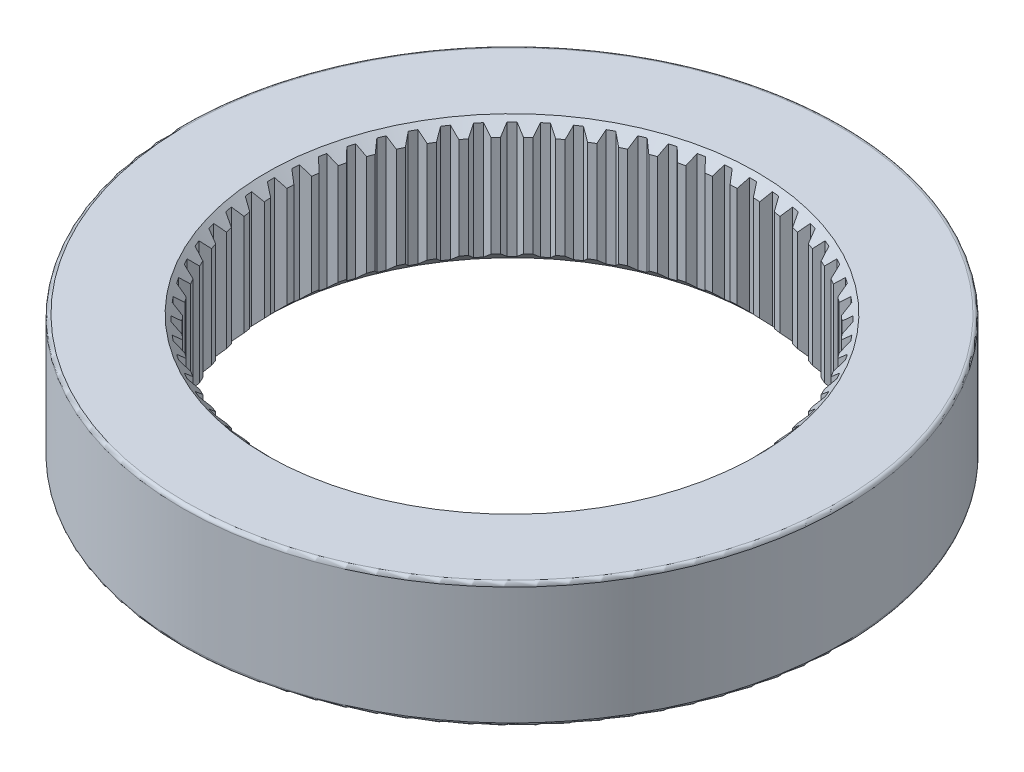
from build123d import *

# Parameters (mm, degrees)
SKETCH1_R           = 35.56
BOSS_EXTRUDE1_DEPTH = 13.462
SKETCH2_R           = 25.1841
CUT_EXTRUDE1_DEPTH  = 40.64
FILLET1_R           = 0.381
FILLET2_R           = 0.381
CHAMFER1_SIZE       = 1.2827
CHAMFER2_SIZE       = 1.2827
CUT_EXTRUDE2_DEPTH  = 13.462


with BuildPart() as part:
    # Sketch1 → Boss-Extrude1 (new body)
    with BuildSketch(Plane(origin=(0, 0, 0), x_dir=(1, 0, 0), z_dir=(0, 1, 0))):
        Circle(SKETCH1_R)
    extrude(amount=BOSS_EXTRUDE1_DEPTH)

    # Sketch2 → Cut-Extrude1 (cut)
    with BuildSketch(Plane(origin=(0, 13.462, 0), x_dir=(1, 0, 0), z_dir=(0, 1, 0))):
        Circle(SKETCH2_R)
    extrude(amount=-CUT_EXTRUDE1_DEPTH, mode=Mode.SUBTRACT)

    # Fillet1
    fillet1_edges = [part.edges().sort_by_distance(p)[0] for p in [
        (-35.56, 13.462, 0),
    ]]
    fillet(fillet1_edges, radius=FILLET1_R)

    # Fillet2
    fillet2_edges = [part.edges().sort_by_distance(p)[0] for p in [
        (-35.56, 0, 0),
    ]]
    fillet(fillet2_edges, radius=FILLET2_R)

    # Chamfer1
    chamfer1_edges = [part.edges().sort_by_distance(p)[0] for p in [
        (-25.1841, 13.462, 0),
    ]]
    chamfer(chamfer1_edges, length=CHAMFER1_SIZE)

    # Chamfer2
    chamfer2_edges = [part.edges().sort_by_distance(p)[0] for p in [
        (-25.1841, 0, 0),
    ]]
    chamfer(chamfer2_edges, length=CHAMFER2_SIZE)

    # Sketch3 → Cut-Extrude2 (cut)
    with BuildSketch(Plane(origin=(0, 13.462, 0), x_dir=(1, 0, 0), z_dir=(0, 1, 0))):
        with BuildLine():
            Line((-26.013050906, 0.384959402), (-25.143050032, 0.887254641))
            ThreePointArc((-25.143050032, 0.887254641), (-25.1587, 0), (-25.143050032, -0.887254641))
            Line((-25.143050032, -0.887254641), (-26.013050906, -0.384959402))
            ThreePointArc((-26.013050906, -0.384959402), (-26.0158992, 0), (-26.013050906, 0.384959402))
        make_face()
        with BuildLine():
            Line((-25.925523576, 2.166619143), (-25.108945536, 1.581467595))
            ThreePointArc((-25.108945536, 1.581467595), (-25.037553983, 2.465983828), (-24.935013211, 3.347432131))
            Line((-24.935013211, 3.347432131), (-25.850058336, 2.932830579))
            ThreePointArc((-25.850058336, 2.932830579), (-25.890625534, 2.550004043), (-25.925523576, 2.166619143))
        make_face()
        with BuildLine():
            Line((-25.588319281, 4.697331962), (-24.833028169, 4.034959435))
            ThreePointArc((-24.833028169, 4.034959435), (-24.675282634, 4.908218885), (-24.486838582, 5.775372019))
            Line((-24.486838582, 5.775372019), (-25.438115573, 5.452456993))
            ThreePointArc((-25.438115573, 5.452456993), (-25.516010992, 5.075450152), (-25.588319281, 4.697331962))
        make_face()
        with BuildLine():
            Line((-25.004685483, 7.182806907), (-24.317955166, 6.449592409))
            ThreePointArc((-24.317955166, 6.449592409), (-24.075374825, 7.30318511), (-23.802842311, 8.147691918))
            Line((-23.802842311, 8.147691918), (-24.781189852, 7.919573266))
            ThreePointArc((-24.781189852, 7.919573266), (-24.895663315, 7.552016903), (-25.004685483, 7.182806907))
        make_face()
        with BuildLine():
            Line((-24.180242896, 9.599107494), (-23.568686961, 8.802112283))
            ThreePointArc((-23.568686961, 8.802112283), (-23.243607995, 9.62781767), (-22.889611658, 10.44154509))
            Line((-22.889611658, 10.44154509), (-23.885607725, 10.31041972))
            ThreePointArc((-23.885607725, 10.31041972), (-24.035556791, 9.955853602), (-24.180242896, 9.599107494))
        make_face()
        with BuildLine():
            Line((-23.122931351, 11.922963429), (-22.592439416, 11.069863004))
            ThreePointArc((-22.592439416, 11.069863004), (-22.187992513, 11.859729083), (-21.755941531, 12.634840474))
            Line((-21.755941531, 12.634840474), (-22.759994139, 12.601971195))
            ThreePointArc((-22.759994139, 12.601971195), (-22.943974716, 12.263809988), (-23.122931351, 11.922963429))
        make_face()
        with BuildLine():
            Line((-21.842933337, 14.131994708), (-21.39861433, 13.231004892))
            ThreePointArc((-21.39861433, 13.231004892), (-20.918694535, 13.977424821), (-20.412749794, 14.706455438))
            Line((-20.412749794, 14.706455438), (-21.415189367, 14.772158798))
            ThreePointArc((-21.415189367, 14.772158798), (-21.631429622, 14.453659181), (-21.842933337, 14.131994708))
        make_face()
        with BuildLine():
            Line((-20.352575934, 16.204927153), (-19.99870889, 15.264724971))
            ThreePointArc((-19.99870889, 15.264724971), (-19.447938093, 15.960510318), (-18.872972118, 16.636439196))
            Line((-18.872972118, 16.636439196), (-19.864144615, 16.800082438))
            ThreePointArc((-19.864144615, 16.800082438), (-20.110562035, 16.504311734), (-20.352575934, 16.204927153))
        make_face()
        with BuildLine():
            Line((-18.666212099, 18.121797291), (-18.406204951, 17.151437403))
            ThreePointArc((-18.406204951, 17.151437403), (-17.789887376, 17.789887376), (-17.151437403, 18.406204951))
            Line((-17.151437403, 18.406204951), (-18.121797291, 18.666212099))
            ThreePointArc((-18.121797291, 18.666212099), (-18.396018743, 18.396018743), (-18.666212099, 18.121797291))
        make_face()
        with BuildLine():
            Line((-16.800082438, 19.864144615), (-16.636439196, 18.872972118))
            ThreePointArc((-16.636439196, 18.872972118), (-15.960510318, 19.447938093), (-15.264724971, 19.99870889))
            Line((-15.264724971, 19.99870889), (-16.204927153, 20.352575934))
            ThreePointArc((-16.204927153, 20.352575934), (-16.504311734, 20.110562035), (-16.800082438, 19.864144615))
        make_face()
        with BuildLine():
            Line((-14.772158798, 21.415189367), (-14.706455438, 20.412749794))
            ThreePointArc((-14.706455438, 20.412749794), (-13.977424821, 20.918694535), (-13.231004892, 21.39861433))
            Line((-13.231004892, 21.39861433), (-14.131994708, 21.842933337))
            ThreePointArc((-14.131994708, 21.842933337), (-14.453659181, 21.631429622), (-14.772158798, 21.415189367))
        make_face()
        with BuildLine():
            Line((-12.601971195, 22.759994139), (-12.634840474, 21.755941531))
            ThreePointArc((-12.634840474, 21.755941531), (-11.859729083, 22.187992513), (-11.069863004, 22.592439416))
            Line((-11.069863004, 22.592439416), (-11.922963429, 23.122931351))
            ThreePointArc((-11.922963429, 23.122931351), (-12.263809988, 22.943974716), (-12.601971195, 22.759994139))
        make_face()
        with BuildLine():
            Line((-10.31041972, 23.885607725), (-10.44154509, 22.889611658))
            ThreePointArc((-10.44154509, 22.889611658), (-9.62781767, 23.243607995), (-8.802112283, 23.568686961))
            Line((-8.802112283, 23.568686961), (-9.599107494, 24.180242896))
            ThreePointArc((-9.599107494, 24.180242896), (-9.955853602, 24.035556791), (-10.31041972, 23.885607725))
        make_face()
        with BuildLine():
            Line((-7.919573266, 24.781189852), (-8.147691918, 23.802842311))
            ThreePointArc((-8.147691918, 23.802842311), (-7.30318511, 24.075374825), (-6.449592409, 24.317955166))
            Line((-6.449592409, 24.317955166), (-7.182806907, 25.004685483))
            ThreePointArc((-7.182806907, 25.004685483), (-7.552016903, 24.895663315), (-7.919573266, 24.781189852))
        make_face()
        with BuildLine():
            Line((-5.452456993, 25.438115573), (-5.775372019, 24.486838582))
            ThreePointArc((-5.775372019, 24.486838582), (-4.908218885, 24.675282634), (-4.034959435, 24.833028169))
            Line((-4.034959435, 24.833028169), (-4.697331962, 25.588319281))
            ThreePointArc((-4.697331962, 25.588319281), (-5.075450152, 25.516010992), (-5.452456993, 25.438115573))
        make_face()
        with BuildLine():
            Line((-2.932830579, 25.850058336), (-3.347432131, 24.935013211))
            ThreePointArc((-3.347432131, 24.935013211), (-2.465983828, 25.037553983), (-1.581467595, 25.108945536))
            Line((-1.581467595, 25.108945536), (-2.166619143, 25.925523576))
            ThreePointArc((-2.166619143, 25.925523576), (-2.550004043, 25.890625534), (-2.932830579, 25.850058336))
        make_face()
        with BuildLine():
            Line((-0.384959402, 26.013050906), (-0.887254641, 25.143050032))
            ThreePointArc((-0.887254641, 25.143050032), (0, 25.1587), (0.887254641, 25.143050032))
            Line((0.887254641, 25.143050032), (0.384959402, 26.013050906))
            ThreePointArc((0.384959402, 26.013050906), (0, 26.0158992), (-0.384959402, 26.013050906))
        make_face()
        with BuildLine():
            Line((2.166619143, 25.925523576), (1.581467595, 25.108945536))
            ThreePointArc((1.581467595, 25.108945536), (2.465983828, 25.037553983), (3.347432131, 24.935013211))
            Line((3.347432131, 24.935013211), (2.932830579, 25.850058336))
            ThreePointArc((2.932830579, 25.850058336), (2.550004043, 25.890625534), (2.166619143, 25.925523576))
        make_face()
        with BuildLine():
            Line((4.697331962, 25.588319281), (4.034959435, 24.833028169))
            ThreePointArc((4.034959435, 24.833028169), (4.908218885, 24.675282634), (5.775372019, 24.486838582))
            Line((5.775372019, 24.486838582), (5.452456993, 25.438115573))
            ThreePointArc((5.452456993, 25.438115573), (5.075450152, 25.516010992), (4.697331962, 25.588319281))
        make_face()
        with BuildLine():
            Line((7.182806907, 25.004685483), (6.449592409, 24.317955166))
            ThreePointArc((6.449592409, 24.317955166), (7.30318511, 24.075374825), (8.147691918, 23.802842311))
            Line((8.147691918, 23.802842311), (7.919573266, 24.781189852))
            ThreePointArc((7.919573266, 24.781189852), (7.552016903, 24.895663315), (7.182806907, 25.004685483))
        make_face()
        with BuildLine():
            Line((9.599107494, 24.180242896), (8.802112283, 23.568686961))
            ThreePointArc((8.802112283, 23.568686961), (9.62781767, 23.243607995), (10.44154509, 22.889611658))
            Line((10.44154509, 22.889611658), (10.31041972, 23.885607725))
            ThreePointArc((10.31041972, 23.885607725), (9.955853602, 24.035556791), (9.599107494, 24.180242896))
        make_face()
        with BuildLine():
            Line((11.922963429, 23.122931351), (11.069863004, 22.592439416))
            ThreePointArc((11.069863004, 22.592439416), (11.859729083, 22.187992513), (12.634840474, 21.755941531))
            Line((12.634840474, 21.755941531), (12.601971195, 22.759994139))
            ThreePointArc((12.601971195, 22.759994139), (12.263809988, 22.943974716), (11.922963429, 23.122931351))
        make_face()
        with BuildLine():
            Line((14.131994708, 21.842933337), (13.231004892, 21.39861433))
            ThreePointArc((13.231004892, 21.39861433), (13.977424821, 20.918694535), (14.706455438, 20.412749794))
            Line((14.706455438, 20.412749794), (14.772158798, 21.415189367))
            ThreePointArc((14.772158798, 21.415189367), (14.453659181, 21.631429622), (14.131994708, 21.842933337))
        make_face()
        with BuildLine():
            Line((16.204927153, 20.352575934), (15.264724971, 19.99870889))
            ThreePointArc((15.264724971, 19.99870889), (15.960510318, 19.447938093), (16.636439196, 18.872972118))
            Line((16.636439196, 18.872972118), (16.800082438, 19.864144615))
            ThreePointArc((16.800082438, 19.864144615), (16.504311734, 20.110562035), (16.204927153, 20.352575934))
        make_face()
        with BuildLine():
            Line((18.121797291, 18.666212099), (17.151437403, 18.406204951))
            ThreePointArc((17.151437403, 18.406204951), (17.789887376, 17.789887376), (18.406204951, 17.151437403))
            Line((18.406204951, 17.151437403), (18.666212099, 18.121797291))
            ThreePointArc((18.666212099, 18.121797291), (18.396018743, 18.396018743), (18.121797291, 18.666212099))
        make_face()
        with BuildLine():
            Line((19.864144615, 16.800082438), (18.872972118, 16.636439196))
            ThreePointArc((18.872972118, 16.636439196), (19.447938093, 15.960510318), (19.99870889, 15.264724971))
            Line((19.99870889, 15.264724971), (20.352575934, 16.204927153))
            ThreePointArc((20.352575934, 16.204927153), (20.110562035, 16.504311734), (19.864144615, 16.800082438))
        make_face()
        with BuildLine():
            Line((21.415189367, 14.772158798), (20.412749794, 14.706455438))
            ThreePointArc((20.412749794, 14.706455438), (20.918694535, 13.977424821), (21.39861433, 13.231004892))
            Line((21.39861433, 13.231004892), (21.842933337, 14.131994708))
            ThreePointArc((21.842933337, 14.131994708), (21.631429622, 14.453659181), (21.415189367, 14.772158798))
        make_face()
        with BuildLine():
            Line((22.759994139, 12.601971195), (21.755941531, 12.634840474))
            ThreePointArc((21.755941531, 12.634840474), (22.187992513, 11.859729083), (22.592439416, 11.069863004))
            Line((22.592439416, 11.069863004), (23.122931351, 11.922963429))
            ThreePointArc((23.122931351, 11.922963429), (22.943974716, 12.263809988), (22.759994139, 12.601971195))
        make_face()
        with BuildLine():
            Line((23.885607725, 10.31041972), (22.889611658, 10.44154509))
            ThreePointArc((22.889611658, 10.44154509), (23.243607995, 9.62781767), (23.568686961, 8.802112283))
            Line((23.568686961, 8.802112283), (24.180242896, 9.599107494))
            ThreePointArc((24.180242896, 9.599107494), (24.035556791, 9.955853602), (23.885607725, 10.31041972))
        make_face()
        with BuildLine():
            Line((24.781189852, 7.919573266), (23.802842311, 8.147691918))
            ThreePointArc((23.802842311, 8.147691918), (24.075374825, 7.30318511), (24.317955166, 6.449592409))
            Line((24.317955166, 6.449592409), (25.004685483, 7.182806907))
            ThreePointArc((25.004685483, 7.182806907), (24.895663315, 7.552016903), (24.781189852, 7.919573266))
        make_face()
        with BuildLine():
            Line((25.438115573, 5.452456993), (24.486838582, 5.775372019))
            ThreePointArc((24.486838582, 5.775372019), (24.675282634, 4.908218885), (24.833028169, 4.034959435))
            Line((24.833028169, 4.034959435), (25.588319281, 4.697331962))
            ThreePointArc((25.588319281, 4.697331962), (25.516010992, 5.075450152), (25.438115573, 5.452456993))
        make_face()
        with BuildLine():
            Line((25.850058336, 2.932830579), (24.935013211, 3.347432131))
            ThreePointArc((24.935013211, 3.347432131), (25.037553983, 2.465983828), (25.108945536, 1.581467595))
            Line((25.108945536, 1.581467595), (25.925523576, 2.166619143))
            ThreePointArc((25.925523576, 2.166619143), (25.890625534, 2.550004043), (25.850058336, 2.932830579))
        make_face()
        with BuildLine():
            Line((26.013050906, 0.384959402), (25.143050032, 0.887254641))
            ThreePointArc((25.143050032, 0.887254641), (25.1587, 0), (25.143050032, -0.887254641))
            Line((25.143050032, -0.887254641), (26.013050906, -0.384959402))
            ThreePointArc((26.013050906, -0.384959402), (26.0158992, 0), (26.013050906, 0.384959402))
        make_face()
        with BuildLine():
            Line((25.925523576, -2.166619143), (25.108945536, -1.581467595))
            ThreePointArc((25.108945536, -1.581467595), (25.037553983, -2.465983828), (24.935013211, -3.347432131))
            Line((24.935013211, -3.347432131), (25.850058336, -2.932830579))
            ThreePointArc((25.850058336, -2.932830579), (25.890625534, -2.550004043), (25.925523576, -2.166619143))
        make_face()
        with BuildLine():
            Line((25.588319281, -4.697331962), (24.833028169, -4.034959435))
            ThreePointArc((24.833028169, -4.034959435), (24.675282634, -4.908218885), (24.486838582, -5.775372019))
            Line((24.486838582, -5.775372019), (25.438115573, -5.452456993))
            ThreePointArc((25.438115573, -5.452456993), (25.516010992, -5.075450152), (25.588319281, -4.697331962))
        make_face()
        with BuildLine():
            Line((25.004685483, -7.182806907), (24.317955166, -6.449592409))
            ThreePointArc((24.317955166, -6.449592409), (24.075374825, -7.30318511), (23.802842311, -8.147691918))
            Line((23.802842311, -8.147691918), (24.781189852, -7.919573266))
            ThreePointArc((24.781189852, -7.919573266), (24.895663315, -7.552016903), (25.004685483, -7.182806907))
        make_face()
        with BuildLine():
            Line((24.180242896, -9.599107494), (23.568686961, -8.802112283))
            ThreePointArc((23.568686961, -8.802112283), (23.243607995, -9.62781767), (22.889611658, -10.44154509))
            Line((22.889611658, -10.44154509), (23.885607725, -10.31041972))
            ThreePointArc((23.885607725, -10.31041972), (24.035556791, -9.955853602), (24.180242896, -9.599107494))
        make_face()
        with BuildLine():
            Line((23.122931351, -11.922963429), (22.592439416, -11.069863004))
            ThreePointArc((22.592439416, -11.069863004), (22.187992513, -11.859729083), (21.755941531, -12.634840474))
            Line((21.755941531, -12.634840474), (22.759994139, -12.601971195))
            ThreePointArc((22.759994139, -12.601971195), (22.943974716, -12.263809988), (23.122931351, -11.922963429))
        make_face()
        with BuildLine():
            Line((21.842933337, -14.131994708), (21.39861433, -13.231004892))
            ThreePointArc((21.39861433, -13.231004892), (20.918694535, -13.977424821), (20.412749794, -14.706455438))
            Line((20.412749794, -14.706455438), (21.415189367, -14.772158798))
            ThreePointArc((21.415189367, -14.772158798), (21.631429622, -14.453659181), (21.842933337, -14.131994708))
        make_face()
        with BuildLine():
            Line((20.352575934, -16.204927153), (19.99870889, -15.264724971))
            ThreePointArc((19.99870889, -15.264724971), (19.447938093, -15.960510318), (18.872972118, -16.636439196))
            Line((18.872972118, -16.636439196), (19.864144615, -16.800082438))
            ThreePointArc((19.864144615, -16.800082438), (20.110562035, -16.504311734), (20.352575934, -16.204927153))
        make_face()
        with BuildLine():
            Line((18.666212099, -18.121797291), (18.406204951, -17.151437403))
            ThreePointArc((18.406204951, -17.151437403), (17.789887376, -17.789887376), (17.151437403, -18.406204951))
            Line((17.151437403, -18.406204951), (18.121797291, -18.666212099))
            ThreePointArc((18.121797291, -18.666212099), (18.396018743, -18.396018743), (18.666212099, -18.121797291))
        make_face()
        with BuildLine():
            Line((16.800082438, -19.864144615), (16.636439196, -18.872972118))
            ThreePointArc((16.636439196, -18.872972118), (15.960510318, -19.447938093), (15.264724971, -19.99870889))
            Line((15.264724971, -19.99870889), (16.204927153, -20.352575934))
            ThreePointArc((16.204927153, -20.352575934), (16.504311734, -20.110562035), (16.800082438, -19.864144615))
        make_face()
        with BuildLine():
            Line((14.772158798, -21.415189367), (14.706455438, -20.412749794))
            ThreePointArc((14.706455438, -20.412749794), (13.977424821, -20.918694535), (13.231004892, -21.39861433))
            Line((13.231004892, -21.39861433), (14.131994708, -21.842933337))
            ThreePointArc((14.131994708, -21.842933337), (14.453659181, -21.631429622), (14.772158798, -21.415189367))
        make_face()
        with BuildLine():
            Line((12.601971195, -22.759994139), (12.634840474, -21.755941531))
            ThreePointArc((12.634840474, -21.755941531), (11.859729083, -22.187992513), (11.069863004, -22.592439416))
            Line((11.069863004, -22.592439416), (11.922963429, -23.122931351))
            ThreePointArc((11.922963429, -23.122931351), (12.263809988, -22.943974716), (12.601971195, -22.759994139))
        make_face()
        with BuildLine():
            Line((10.31041972, -23.885607725), (10.44154509, -22.889611658))
            ThreePointArc((10.44154509, -22.889611658), (9.62781767, -23.243607995), (8.802112283, -23.568686961))
            Line((8.802112283, -23.568686961), (9.599107494, -24.180242896))
            ThreePointArc((9.599107494, -24.180242896), (9.955853602, -24.035556791), (10.31041972, -23.885607725))
        make_face()
        with BuildLine():
            Line((7.919573266, -24.781189852), (8.147691918, -23.802842311))
            ThreePointArc((8.147691918, -23.802842311), (7.30318511, -24.075374825), (6.449592409, -24.317955166))
            Line((6.449592409, -24.317955166), (7.182806907, -25.004685483))
            ThreePointArc((7.182806907, -25.004685483), (7.552016903, -24.895663315), (7.919573266, -24.781189852))
        make_face()
        with BuildLine():
            Line((5.452456993, -25.438115573), (5.775372019, -24.486838582))
            ThreePointArc((5.775372019, -24.486838582), (4.908218885, -24.675282634), (4.034959435, -24.833028169))
            Line((4.034959435, -24.833028169), (4.697331962, -25.588319281))
            ThreePointArc((4.697331962, -25.588319281), (5.075450152, -25.516010992), (5.452456993, -25.438115573))
        make_face()
        with BuildLine():
            Line((2.932830579, -25.850058336), (3.347432131, -24.935013211))
            ThreePointArc((3.347432131, -24.935013211), (2.465983828, -25.037553983), (1.581467595, -25.108945536))
            Line((1.581467595, -25.108945536), (2.166619143, -25.925523576))
            ThreePointArc((2.166619143, -25.925523576), (2.550004043, -25.890625534), (2.932830579, -25.850058336))
        make_face()
        with BuildLine():
            Line((0.384959402, -26.013050906), (0.887254641, -25.143050032))
            ThreePointArc((0.887254641, -25.143050032), (0, -25.1587), (-0.887254641, -25.143050032))
            Line((-0.887254641, -25.143050032), (-0.384959402, -26.013050906))
            ThreePointArc((-0.384959402, -26.013050906), (0, -26.0158992), (0.384959402, -26.013050906))
        make_face()
        with BuildLine():
            Line((-2.166619143, -25.925523576), (-1.581467595, -25.108945536))
            ThreePointArc((-1.581467595, -25.108945536), (-2.465983828, -25.037553983), (-3.347432131, -24.935013211))
            Line((-3.347432131, -24.935013211), (-2.932830579, -25.850058336))
            ThreePointArc((-2.932830579, -25.850058336), (-2.550004043, -25.890625534), (-2.166619143, -25.925523576))
        make_face()
        with BuildLine():
            Line((-4.697331962, -25.588319281), (-4.034959435, -24.833028169))
            ThreePointArc((-4.034959435, -24.833028169), (-4.908218885, -24.675282634), (-5.775372019, -24.486838582))
            Line((-5.775372019, -24.486838582), (-5.452456993, -25.438115573))
            ThreePointArc((-5.452456993, -25.438115573), (-5.075450152, -25.516010992), (-4.697331962, -25.588319281))
        make_face()
        with BuildLine():
            Line((-7.182806907, -25.004685483), (-6.449592409, -24.317955166))
            ThreePointArc((-6.449592409, -24.317955166), (-7.30318511, -24.075374825), (-8.147691918, -23.802842311))
            Line((-8.147691918, -23.802842311), (-7.919573266, -24.781189852))
            ThreePointArc((-7.919573266, -24.781189852), (-7.552016903, -24.895663315), (-7.182806907, -25.004685483))
        make_face()
        with BuildLine():
            Line((-9.599107494, -24.180242896), (-8.802112283, -23.568686961))
            ThreePointArc((-8.802112283, -23.568686961), (-9.62781767, -23.243607995), (-10.44154509, -22.889611658))
            Line((-10.44154509, -22.889611658), (-10.31041972, -23.885607725))
            ThreePointArc((-10.31041972, -23.885607725), (-9.955853602, -24.035556791), (-9.599107494, -24.180242896))
        make_face()
        with BuildLine():
            Line((-11.922963429, -23.122931351), (-11.069863004, -22.592439416))
            ThreePointArc((-11.069863004, -22.592439416), (-11.859729083, -22.187992513), (-12.634840474, -21.755941531))
            Line((-12.634840474, -21.755941531), (-12.601971195, -22.759994139))
            ThreePointArc((-12.601971195, -22.759994139), (-12.263809988, -22.943974716), (-11.922963429, -23.122931351))
        make_face()
        with BuildLine():
            Line((-14.131994708, -21.842933337), (-13.231004892, -21.39861433))
            ThreePointArc((-13.231004892, -21.39861433), (-13.977424821, -20.918694535), (-14.706455438, -20.412749794))
            Line((-14.706455438, -20.412749794), (-14.772158798, -21.415189367))
            ThreePointArc((-14.772158798, -21.415189367), (-14.453659181, -21.631429622), (-14.131994708, -21.842933337))
        make_face()
        with BuildLine():
            Line((-16.204927153, -20.352575934), (-15.264724971, -19.99870889))
            ThreePointArc((-15.264724971, -19.99870889), (-15.960510318, -19.447938093), (-16.636439196, -18.872972118))
            Line((-16.636439196, -18.872972118), (-16.800082438, -19.864144615))
            ThreePointArc((-16.800082438, -19.864144615), (-16.504311734, -20.110562035), (-16.204927153, -20.352575934))
        make_face()
        with BuildLine():
            Line((-18.121797291, -18.666212099), (-17.151437403, -18.406204951))
            ThreePointArc((-17.151437403, -18.406204951), (-17.789887376, -17.789887376), (-18.406204951, -17.151437403))
            Line((-18.406204951, -17.151437403), (-18.666212099, -18.121797291))
            ThreePointArc((-18.666212099, -18.121797291), (-18.396018743, -18.396018743), (-18.121797291, -18.666212099))
        make_face()
        with BuildLine():
            Line((-19.864144615, -16.800082438), (-18.872972118, -16.636439196))
            ThreePointArc((-18.872972118, -16.636439196), (-19.447938093, -15.960510318), (-19.99870889, -15.264724971))
            Line((-19.99870889, -15.264724971), (-20.352575934, -16.204927153))
            ThreePointArc((-20.352575934, -16.204927153), (-20.110562035, -16.504311734), (-19.864144615, -16.800082438))
        make_face()
        with BuildLine():
            Line((-21.415189367, -14.772158798), (-20.412749794, -14.706455438))
            ThreePointArc((-20.412749794, -14.706455438), (-20.918694535, -13.977424821), (-21.39861433, -13.231004892))
            Line((-21.39861433, -13.231004892), (-21.842933337, -14.131994708))
            ThreePointArc((-21.842933337, -14.131994708), (-21.631429622, -14.453659181), (-21.415189367, -14.772158798))
        make_face()
        with BuildLine():
            Line((-22.759994139, -12.601971195), (-21.755941531, -12.634840474))
            ThreePointArc((-21.755941531, -12.634840474), (-22.187992513, -11.859729083), (-22.592439416, -11.069863004))
            Line((-22.592439416, -11.069863004), (-23.122931351, -11.922963429))
            ThreePointArc((-23.122931351, -11.922963429), (-22.943974716, -12.263809988), (-22.759994139, -12.601971195))
        make_face()
        with BuildLine():
            Line((-23.885607725, -10.31041972), (-22.889611658, -10.44154509))
            ThreePointArc((-22.889611658, -10.44154509), (-23.243607995, -9.62781767), (-23.568686961, -8.802112283))
            Line((-23.568686961, -8.802112283), (-24.180242896, -9.599107494))
            ThreePointArc((-24.180242896, -9.599107494), (-24.035556791, -9.955853602), (-23.885607725, -10.31041972))
        make_face()
        with BuildLine():
            Line((-24.781189852, -7.919573266), (-23.802842311, -8.147691918))
            ThreePointArc((-23.802842311, -8.147691918), (-24.075374825, -7.30318511), (-24.317955166, -6.449592409))
            Line((-24.317955166, -6.449592409), (-25.004685483, -7.182806907))
            ThreePointArc((-25.004685483, -7.182806907), (-24.895663315, -7.552016903), (-24.781189852, -7.919573266))
        make_face()
        with BuildLine():
            Line((-25.438115573, -5.452456993), (-24.486838582, -5.775372019))
            ThreePointArc((-24.486838582, -5.775372019), (-24.675282634, -4.908218885), (-24.833028169, -4.034959435))
            Line((-24.833028169, -4.034959435), (-25.588319281, -4.697331962))
            ThreePointArc((-25.588319281, -4.697331962), (-25.516010992, -5.075450152), (-25.438115573, -5.452456993))
        make_face()
        with BuildLine():
            Line((-25.850058336, -2.932830579), (-24.935013211, -3.347432131))
            ThreePointArc((-24.935013211, -3.347432131), (-25.037553983, -2.465983828), (-25.108945536, -1.581467595))
            Line((-25.108945536, -1.581467595), (-25.925523576, -2.166619143))
            ThreePointArc((-25.925523576, -2.166619143), (-25.890625534, -2.550004043), (-25.850058336, -2.932830579))
        make_face()
    extrude(amount=-CUT_EXTRUDE2_DEPTH, mode=Mode.SUBTRACT)


solid = part.part
